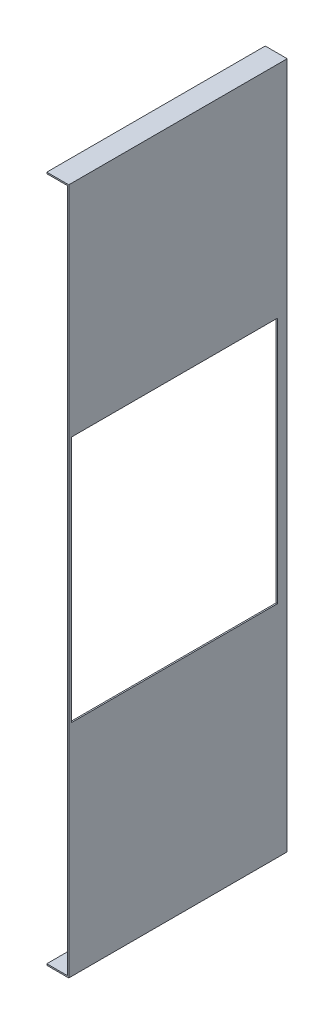
from build123d import *

# Parameters (mm, degrees)
BOSS_EXTRUDE1_DEPTH = 159
SKETCH3_W           = 150
SKETCH3_H           = 180
CUT_EXTRUDE1_DEPTH  = 17


with BuildPart() as part:
    # Sketch1 → Boss-Extrude1 (new body)
    with BuildSketch(Plane.XY):
        Polygon((-0.5, -249), (-15.5, -249), (-15.5, -250), (0.5, -250), (0.5, -249), (0.5, 249), (0.5, 250), (-15.5, 250), (-15.5, 249), (-0.5, 249), align=None)
    extrude(amount=BOSS_EXTRUDE1_DEPTH)

    # Sketch3 → Cut-Extrude1 (cut, through all)
    with BuildSketch(Plane(origin=(0.5, 0, 0), x_dir=(0, 0, -1), z_dir=(1, 0, 0))):
        with Locations((-82, 0)):
            Rectangle(SKETCH3_W, SKETCH3_H)
    extrude(amount=-CUT_EXTRUDE1_DEPTH, mode=Mode.SUBTRACT)


solid = part.part
